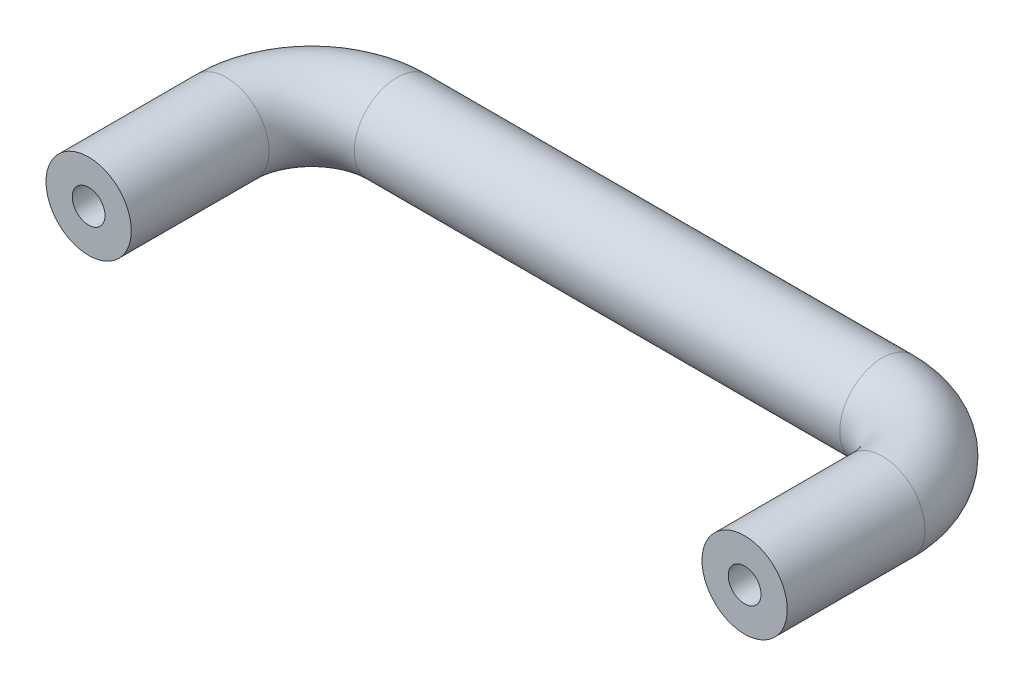
from build123d import *

# Parameters (mm, degrees)
SWEEP1_PROFILE_R                = 6.5
TAP_DRILL_FOR_M6X1_0_TAP1_D     = 5
TAP_DRILL_FOR_M6X1_0_TAP1_DEPTH = 22
TAP_DRILL_FOR_M6X1_0_TAP1_TIP   = 1.502151548


with BuildPart() as part:
    # Sweep1: sweep along a path in Sketch1
    with BuildLine(Plane(origin=(0, 0, 0), x_dir=(1, 0, 0), z_dir=(0, 1, 0))) as sweep1_path:
        Line((-50, -34), (-50, -13))
        ThreePointArc((-50, -13), (-46.192388155, -3.807611845), (-37, 0))
        Line((-37, 0), (37, 0))
        ThreePointArc((37, 0), (46.192388155, -3.807611845), (50, -13))
        Line((50, -13), (50, -34))
    # Sweep1 profile (on start of the path) → Sweep1 (sweep)
    with BuildSketch(Plane(origin=(-50, 0, 34), x_dir=(-1, 0, 0), z_dir=(0, 0, -1))):
        Circle(SWEEP1_PROFILE_R)
    sweep(path=sweep1_path.line)

    # Tap Drill for M6x1.0 Tap1
    with Locations(Plane.XY.offset(34)):
        with Locations((-50, 0), (50, 0)):
            Hole(TAP_DRILL_FOR_M6X1_0_TAP1_D / 2, depth=TAP_DRILL_FOR_M6X1_0_TAP1_DEPTH)
            with Locations((0, 0, -(TAP_DRILL_FOR_M6X1_0_TAP1_DEPTH + TAP_DRILL_FOR_M6X1_0_TAP1_TIP / 2))):  # 118° drill point
                Cone(0, TAP_DRILL_FOR_M6X1_0_TAP1_D / 2, TAP_DRILL_FOR_M6X1_0_TAP1_TIP, mode=Mode.SUBTRACT)


solid = part.part
